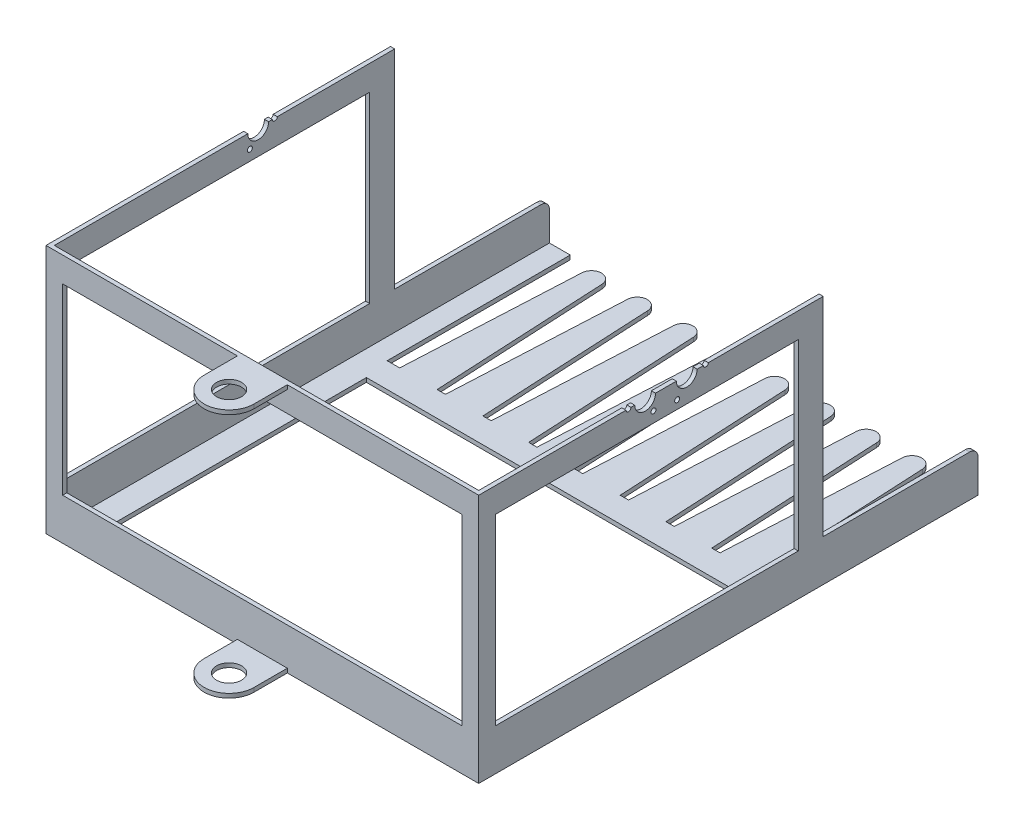
from build123d import *

# Parameters (mm, degrees)
EXTRUDE_1_DEPTH      = 300
SKETCH_2_W           = 480
SKETCH_2_H           = 220
CUT_EXTRUDE_1_DEPTH  = 601
SKETCH_3_W           = 364
SKETCH_3_H           = 220
CUT_EXTRUDE_2_DEPTH  = 520
SKETCH_5_W           = 186
SKETCH_5_H           = 250
CUT_EXTRUDE_4_DEPTH  = 520
SKETCH_6_W           = 510
SKETCH_6_H           = 800
CUT_EXTRUDE_5_DEPTH  = 295
CUT_EXTRUDE_3_REACH  = 522
SKETCH_4_R           = 12.5
SKETCH_12_R          = 12.5
CUT_EXTRUDE_8_DEPTH  = 10
SKETCH_7_R           = 15
EXTRUDE_2_DEPTH      = 300
CUT_EXTRUDE_6_REACH  = 292
SKETCH_8_W           = 177.621372849
SKETCH_8_H           = 290
SKETCH_10_W          = 450
SKETCH_10_H          = 315
CUT_EXTRUDE_7_DEPTH  = 51
FILLET_1_R           = 10
SKETCH_15_R          = 3
CUT_EXTRUDE_10_DEPTH = 5
SKETCH_16_R          = 3
CUT_EXTRUDE_11_DEPTH = 5
SKETCH_17_R          = 3
CUT_EXTRUDE_12_DEPTH = 5


with BuildPart() as part:
    # 草图1 → 凸台-拉伸1 (new body)
    with BuildSketch(Plane(origin=(0, 0, 0), x_dir=(1, 0, 0), z_dir=(0, 1, 0))):
        with BuildLine():
            Line((-215, 80), (-230, 80))
            Line((-230, 80), (-230, 300))
            Line((-230, 300), (-260, 300))
            Line((-260, 300), (-260, -300))
            Line((-260, -300), (260, -300))
            Line((260, -300), (260, 300))
            Line((260, 300), (230, 300))
            Line((230, 300), (230, 80))
            Line((230, 80), (215, 80))
            Line((215, 80), (204.484783483, 288.604123213))
            ThreePointArc((204.484783483, 288.604123213), (192.5, 300), (180.515216517, 288.604123213))
            Line((180.515216517, 288.604123213), (170, 80))
            Line((170, 80), (160, 80))
            Line((160, 80), (149.484783483, 288.604123213))
            ThreePointArc((149.484783483, 288.604123213), (137.5, 300), (125.515216517, 288.604123213))
            Line((125.515216517, 288.604123213), (115, 80))
            Line((115, 80), (105, 80))
            Line((105, 80), (94.484783483, 288.604123213))
            ThreePointArc((94.484783483, 288.604123213), (82.5, 300), (70.515216517, 288.604123213))
            Line((70.515216517, 288.604123213), (60, 80))
            Line((60, 80), (50, 80))
            Line((50, 80), (39.484783483, 288.604123213))
            ThreePointArc((39.484783483, 288.604123213), (27.5, 300), (15.515216517, 288.604123213))
            Line((15.515216517, 288.604123213), (5, 80))
            Line((5, 80), (-5, 80))
            Line((-5, 80), (-15.515216517, 288.604123213))
            ThreePointArc((-15.515216517, 288.604123213), (-27.5, 300), (-39.484783483, 288.604123213))
            Line((-39.484783483, 288.604123213), (-50, 80))
            Line((-50, 80), (-60, 80))
            Line((-60, 80), (-70.515216517, 288.604123213))
            ThreePointArc((-70.515216517, 288.604123213), (-82.5, 300), (-94.484783483, 288.604123213))
            Line((-94.484783483, 288.604123213), (-105, 80))
            Line((-105, 80), (-115, 80))
            Line((-115, 80), (-125.515216517, 288.604123213))
            ThreePointArc((-125.515216517, 288.604123213), (-137.5, 300), (-149.484783483, 288.604123213))
            Line((-149.484783483, 288.604123213), (-160, 80))
            Line((-160, 80), (-170, 80))
            Line((-170, 80), (-180.515216517, 288.604123213))
            ThreePointArc((-180.515216517, 288.604123213), (-192.5, 300), (-204.484783483, 288.604123213))
            Line((-204.484783483, 288.604123213), (-215, 80))
        make_face()
    extrude(amount=EXTRUDE_1_DEPTH)

    # 草图2 → 切除-拉伸1 (cut, through all)
    with BuildSketch(Plane.XY.offset(300)):
        with Locations((0, 160)):
            Rectangle(SKETCH_2_W, SKETCH_2_H)
    extrude(amount=-CUT_EXTRUDE_1_DEPTH, mode=Mode.SUBTRACT)

    # 草图3 → 切除-拉伸2 (cut)
    with BuildSketch(Plane.ZY.offset(260)):
        with Locations((98, 160)):
            Rectangle(SKETCH_3_W, SKETCH_3_H)
    extrude(amount=-CUT_EXTRUDE_2_DEPTH, mode=Mode.SUBTRACT)

    # 草图5 → 切除-拉伸4 (cut)
    with BuildSketch(Plane.ZY.offset(260)):
        with Locations((-207, 175)):
            Rectangle(SKETCH_5_W, SKETCH_5_H)
    extrude(amount=-CUT_EXTRUDE_4_DEPTH, mode=Mode.SUBTRACT)

    # 草图6 → 切除-拉伸5 (cut)
    with BuildSketch(Plane(origin=(0, 300, 0), x_dir=(1, 0, 0), z_dir=(0, 1, 0))):
        with Locations((0, 105)):
            Rectangle(SKETCH_6_W, SKETCH_6_H)
    extrude(amount=-CUT_EXTRUDE_5_DEPTH, mode=Mode.SUBTRACT)

    # 草图4 → 切除-拉伸3 (cut, up to next)
    with BuildSketch(Plane.ZY.offset(260), mode=Mode.PRIVATE) as cut_extrude_3_sk1:
        with Locations((50, 300)):
            Circle(SKETCH_4_R)
    cut_extrude_3_tool1 = extrude(cut_extrude_3_sk1.sketch, amount=-CUT_EXTRUDE_3_REACH, mode=Mode.PRIVATE) & part.part
    add(cut_extrude_3_tool1.solids().sort_by_distance((-260, 300, 50))[0], mode=Mode.SUBTRACT)

    # 草图12 → 切除-拉伸8 (cut)
    with BuildSketch(Plane(origin=(260, 0, 0), x_dir=(0, 0, -1), z_dir=(1, 0, 0))):
        with Locations((-100, 300)):
            Circle(SKETCH_12_R)
        with Locations((-50, 300)):
            Circle(SKETCH_12_R)
    extrude(amount=-CUT_EXTRUDE_8_DEPTH, mode=Mode.SUBTRACT)

    # 草图7 → 凸台-拉伸2 (add)
    with BuildSketch(Plane(origin=(0, 300, 0), x_dir=(1, 0, 0), z_dir=(0, 1, 0))):
        with BuildLine():
            Line((-30, -340), (-30, -300))
            Line((-30, -300), (30, -300))
            Line((30, -300), (30, -340))
            ThreePointArc((30, -340), (0, -370), (-30, -340))
        make_face()
        with Locations((0, -340)):
            Circle(SKETCH_7_R, mode=Mode.SUBTRACT)
    extrude(amount=-EXTRUDE_2_DEPTH)

    # 草图8 → 切除-拉伸6 (cut, up to next)
    with BuildSketch(Plane.ZY.offset(30), mode=Mode.PRIVATE) as cut_extrude_6_sk1:
        with Locations((388.810686424, 150)):
            Rectangle(SKETCH_8_W, SKETCH_8_H)
    cut_extrude_6_tool1 = extrude(cut_extrude_6_sk1.sketch, amount=-CUT_EXTRUDE_6_REACH, mode=Mode.PRIVATE) & part.part
    add(cut_extrude_6_tool1.solids().sort_by_distance((-30, 150, 388.810686))[0], mode=Mode.SUBTRACT)

    # 草图10 → 切除-拉伸7 (cut, through all)
    with BuildSketch(Plane(origin=(0, 50, 0), x_dir=(1, 0, 0), z_dir=(0, 1, 0))):
        with Locations((0, -107.5)):
            Rectangle(SKETCH_10_W, SKETCH_10_H)
    extrude(amount=-CUT_EXTRUDE_7_DEPTH, mode=Mode.SUBTRACT)

    # 圆角1
    fillet_1_edges = [part.edges().sort_by_distance(p)[0] for p in [
        (-257.5, 50, -300),
        (257.5, 50, -300),
    ]]
    fillet(fillet_1_edges, radius=FILLET_1_R)

    # 草图15 → 切除-拉伸10 (cut)
    with BuildSketch(Plane(origin=(260, 0, 0), x_dir=(0, 0, -1), z_dir=(1, 0, 0))):
        with Locations((-120, 300)):
            Circle(SKETCH_15_R)
        with Locations((-90, 282.679491924)):
            Circle(SKETCH_15_R)
    extrude(amount=-CUT_EXTRUDE_10_DEPTH, mode=Mode.SUBTRACT)

    # 草图16 → 切除-拉伸11 (cut)
    with BuildSketch(Plane.ZY.offset(260)):
        with Locations((30, 300)):
            Circle(SKETCH_16_R)
        with Locations((60, 282.679491924)):
            Circle(SKETCH_16_R)
    extrude(amount=-CUT_EXTRUDE_11_DEPTH, mode=Mode.SUBTRACT)

    # 草图17 → 切除-拉伸12 (cut)
    with BuildSketch(Plane(origin=(260, 0, 0), x_dir=(0, 0, -1), z_dir=(1, 0, 0))):
        with Locations((-27, 300)):
            Circle(SKETCH_17_R)
        with Locations((-61.5, 280.081415713)):
            Circle(SKETCH_17_R)
    extrude(amount=-CUT_EXTRUDE_12_DEPTH, mode=Mode.SUBTRACT)


solid = part.part
